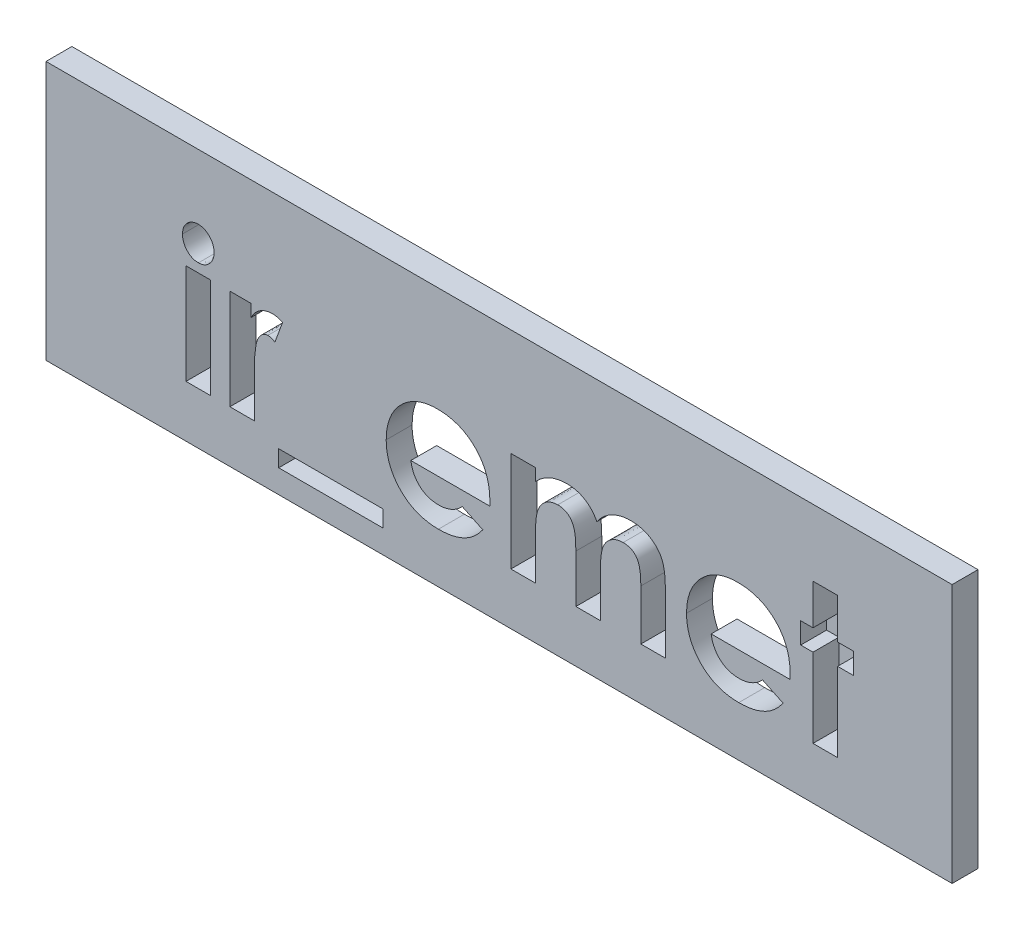
from build123d import *

# Parameters (mm, degrees)
ESQUISSE1_W             = 35
ESQUISSE1_H             = 10
BOSS_EXTRU_1_DEPTH      = 1
ESQUISSE2_R             = 1
BOSS_EXTRU_2_DEPTH      = 3
CHANFREIN1_SIZE         = 0.5
ESQUISSE3_W             = 0.949786325
ESQUISSE3_H             = 3.866987179
ESQUISSE3_W_2           = 3.731303419
ESQUISSE3_H_2           = 0.339209402
ENL_V_MAT_EXTRU_2_DEPTH = 1
ESQUISSE4_W             = 4.031303419
ESQUISSE4_H             = 0.639209402
ENL_V_MAT_EXTRU_3_DEPTH = 5


with BuildPart() as part:
    # Esquisse1 → Boss.-Extru.1 (new body)
    with BuildSketch(Plane.XY):
        with Locations((17.5, -5)):
            Rectangle(ESQUISSE1_W, ESQUISSE1_H)
    extrude(amount=BOSS_EXTRU_1_DEPTH)

    # Esquisse2 → Boss.-Extru.2 (add)
    with BuildSketch(Plane(origin=(0, 0, 0), x_dir=(-1, 0, 0), z_dir=(0, 0, -1))):
        with Locations(Location((-30, -5, 0), (0, 0, 180))):  # turned: the seam where the file's is
            Circle(ESQUISSE2_R)
        with Locations(Location((-5, -5, 0), (0, 0, 180))):  # turned: the seam where the file's is
            Circle(ESQUISSE2_R)
    extrude(amount=BOSS_EXTRU_2_DEPTH)

    # Chanfrein1
    chanfrein1_edges = [part.edges().sort_by_distance(p)[0] for p in [
        (29, -5, -3),
        (4, -5, -3),
    ]]
    chamfer(chanfrein1_edges, length=CHANFREIN1_SIZE)

    # Esquisse3 → Enlèv. mat.-Extru.2 (cut)
    with BuildSketch(Plane.XY.offset(1)):
        with BuildLine():
            add(Edge.make_bspline(
                [(5.879824386, -2.504807692), (5.92076017, -2.506816157), (6.001141525, -2.51075997), (6.116298756, -2.549203379), (6.221989755, -2.609539161), (6.315423529, -2.692321292), (6.393133006, -2.791178297), (6.452505932, -2.901855287), (6.485580115, -3.024481827), (6.49017363, -3.109190958), (6.492521368, -3.152485644)],
                knots=[0, 0, 0, 0, 0.989868614, 1.943702388, 2.910836514, 3.924849579, 4.949916355, 5.946401046, 6.950409252, 8, 8, 8, 8], degree=3))
            add(Edge.make_bspline(
                [(6.492521368, -3.152485644), (6.490257628, -3.195461271), (6.485846625, -3.279201328), (6.451744709, -3.400163155), (6.394754806, -3.510786389), (6.316415931, -3.608175184), (6.223995101, -3.68962406), (6.120613531, -3.751055201), (6.006559841, -3.787360012), (5.927425761, -3.791633507), (5.887244591, -3.793803419)],
                knots=[0, 0, 0, 0, 1.05296456, 2.051751585, 3.055639087, 4.085634717, 5.099016424, 6.062201612, 7.016062274, 8, 8, 8, 8], degree=3))
            add(Edge.make_bspline(
                [(5.887244591, -3.793803419), (5.845951472, -3.791802134), (5.764870802, -3.787872533), (5.648769045, -3.749339175), (5.541668398, -3.689478577), (5.448639939, -3.605005079), (5.370040515, -3.50544562), (5.313261022, -3.392191974), (5.277744044, -3.268726916), (5.27352821, -3.182763185), (5.271367521, -3.138705262)],
                knots=[0, 0, 0, 0, 0.989065327, 1.942068821, 2.907541208, 3.917690034, 4.939857478, 5.938239964, 6.943311734, 8, 8, 8, 8], degree=3))
            add(Edge.make_bspline(
                [(5.271367521, -3.138705262), (5.273718942, -3.096459386), (5.278337968, -3.013473462), (5.31161027, -2.893573269), (5.369621776, -2.784756933), (5.446771504, -2.687709598), (5.539384615, -2.606471665), (5.645012166, -2.547968321), (5.759394385, -2.511112734), (5.839266553, -2.506931074), (5.879824386, -2.504807692)],
                knots=[0, 0, 0, 0, 1.038616768, 2.040212704, 3.031499824, 4.052181184, 5.074969369, 6.039807101, 7.004644834, 8, 8, 8, 8], degree=3))
        make_face()
        with Locations((5.881944445, -6.066506411)):
            Rectangle(ESQUISSE3_W, ESQUISSE3_H)
        with BuildLine():
            Line((7.103098291, -4.133012821), (7.917200855, -4.133012821))
            Line((7.917200855, -4.133012821), (7.917200855, -4.608966012))
            add(Edge.make_bspline(
                [(7.917200855, -4.608966012), (7.940230253, -4.566667921), (7.985242169, -4.483994547), (8.067932832, -4.373021915), (8.162931215, -4.27956386), (8.266823732, -4.201665623), (8.379925261, -4.140951595), (8.499207145, -4.097685197), (8.623648929, -4.069568033), (8.708538895, -4.066647192), (8.751443977, -4.06517094)],
                knots=[0, 0, 0, 0, 1.09866127, 2.147379032, 3.14564304, 4.131443017, 5.102343063, 6.064490016, 7.021754664, 8, 8, 8, 8], degree=3))
            add(Edge.make_bspline(
                [(8.751443977, -4.06517094), (8.78259842, -4.066629785), (8.84603999, -4.069600514), (8.942733871, -4.086869409), (9.040822874, -4.118094854), (9.105373891, -4.146209218), (9.138354701, -4.160573584)],
                knots=[0, 0, 0, 0, 0.931404136, 1.896671404, 2.925354185, 4, 4, 4, 4], degree=3))
            Line((9.138354701, -4.160573584), (8.843666533, -4.965135884))
            add(Edge.make_bspline(
                [(8.843666533, -4.965135884), (8.817325619, -4.952409228), (8.767814841, -4.928488014), (8.695933787, -4.900258516), (8.630698751, -4.883034257), (8.589340935, -4.880464246), (8.570178953, -4.879273504)],
                knots=[0, 0, 0, 0, 1.214386998, 2.282580073, 3.20428172, 4, 4, 4, 4], degree=3))
            add(Edge.make_bspline(
                [(8.570178953, -4.879273504), (8.552086315, -4.880062553), (8.51649498, -4.881614748), (8.463963165, -4.894916529), (8.414489134, -4.917855038), (8.365688737, -4.947241545), (8.321411784, -4.988090988), (8.277162179, -5.03538147), (8.238167059, -5.093767862), (8.197015897, -5.15875488), (8.161977155, -5.238298932), (8.131932512, -5.333258138), (8.105162494, -5.444731242), (8.086741067, -5.57331011), (8.068936018, -5.717750521), (8.058338015, -5.879112649), (8.05043919, -6.056886251), (8.04995623, -6.180978642), (8.049704527, -6.245651376)],
                knots=[0, 0, 0, 0, 0.544232178, 1.070598461, 1.618251235, 2.182094276, 2.777567932, 3.425210017, 4.127676488, 4.886675562, 5.738955394, 6.734782583, 7.883056018, 9.186093582, 10.642914445, 12.264202625, 14.053029461, 16, 16, 16, 16], degree=3))
            Line((8.049704527, -6.245651376), (8.052884615, -6.434336605))
            Line((8.052884615, -6.434336605), (8.052884615, -8))
            Line((8.052884615, -8), (7.103098291, -8))
            Line((7.103098291, -8), (7.103098291, -4.133012821))
        make_face()
        with Locations((11.004006411, -8.780181624)):
            Rectangle(ESQUISSE3_W_2, ESQUISSE3_H_2)
        with BuildLine():
            Line((17.140516493, -6.303952991), (14.090811966, -6.303952991))
            add(Edge.make_bspline(
                [(14.090811966, -6.303952991), (14.097030067, -6.339388828), (14.109249127, -6.409023042), (14.135783249, -6.510172781), (14.169644768, -6.605494587), (14.210225667, -6.695115884), (14.256841751, -6.779510462), (14.311215552, -6.858282479), (14.372657386, -6.931362358), (14.440812014, -6.998432487), (14.514543421, -7.058528775), (14.593494038, -7.111176923), (14.677745337, -7.154345184), (14.766331408, -7.190731548), (14.859914193, -7.219553234), (14.958631422, -7.239431004), (15.062221412, -7.251172875), (15.132790077, -7.252871202), (15.168861846, -7.253739316)],
                knots=[0, 0, 0, 0, 1.091296461, 2.144483647, 3.168565212, 4.157007626, 5.126487748, 6.090021542, 7.05641414, 8.019231907, 8.98705074, 9.938580405, 10.892824166, 11.854447369, 12.841318655, 13.858982407, 14.905600794, 16, 16, 16, 16], degree=3))
            add(Edge.make_bspline(
                [(15.168861846, -7.253739316), (15.212402919, -7.25258979), (15.298148115, -7.250326034), (15.423765466, -7.23024988), (15.545255743, -7.199925733), (15.66146922, -7.15483118), (15.773752046, -7.098696389), (15.880255704, -7.028759346), (15.982823686, -6.947063841), (16.045402242, -6.884092976), (16.077307025, -6.851988181)],
                knots=[0, 0, 0, 0, 1.021034703, 2.010718019, 2.977989445, 3.954245119, 4.929443971, 5.918328161, 6.938689359, 8, 8, 8, 8], degree=3))
            Line((16.077307025, -6.851988181), (16.87232906, -7.23041867))
            add(Edge.make_bspline(
                [(16.87232906, -7.23041867), (16.847298255, -7.2650074), (16.797700636, -7.333543698), (16.716734187, -7.42999197), (16.632240542, -7.51998212), (16.544156686, -7.602922269), (16.452370906, -7.678576072), (16.357138528, -7.747865128), (16.257067769, -7.808929053), (16.154159528, -7.864722083), (16.046286499, -7.91255319), (15.933747216, -7.953341869), (15.817018344, -7.990214488), (15.694625851, -8.018309404), (15.567588898, -8.04054911), (15.435603588, -8.056342248), (15.298687315, -8.066096912), (15.205626122, -8.067253315), (15.158261552, -8.06784188)],
                knots=[0, 0, 0, 0, 1.028154879, 2.037251081, 3.030720504, 4.000128189, 4.949298328, 5.894184978, 6.834267904, 7.770992897, 8.712077017, 9.673380525, 10.653304757, 11.658697181, 12.695551717, 13.758623199, 14.859225354, 16, 16, 16, 16], degree=3))
            add(Edge.make_bspline(
                [(15.158261552, -8.06784188), (15.085391938, -8.066356288), (14.942680999, -8.063446841), (14.733940453, -8.036443012), (14.53569483, -7.991667753), (14.347384355, -7.930802664), (14.16982303, -7.85044168), (14.00292298, -7.752153529), (13.845016634, -7.637822594), (13.700928914, -7.505049371), (13.56966075, -7.360533612), (13.454362956, -7.205333555), (13.357883404, -7.040533524), (13.278652456, -6.867224201), (13.217071411, -6.684961981), (13.172675049, -6.49366733), (13.145459547, -6.293431612), (13.142520138, -6.157048736), (13.141025641, -6.087706998)],
                knots=[0, 0, 0, 0, 1.103565453, 2.161269334, 3.182010356, 4.179077853, 5.15417608, 6.128274628, 7.109042802, 8.101804412, 9.090965879, 10.063106201, 11.02526161, 11.978650795, 12.945248442, 13.93468508, 14.949922959, 16, 16, 16, 16], degree=3))
            add(Edge.make_bspline(
                [(13.141025641, -6.087706998), (13.142534847, -6.016603197), (13.145504141, -5.876709662), (13.172440723, -5.67185041), (13.217194151, -5.476386975), (13.278955335, -5.290050184), (13.35698434, -5.112257255), (13.454691429, -4.944563662), (13.569603534, -4.786385588), (13.700398807, -4.638463007), (13.845096927, -4.504946716), (13.998852351, -4.385957019), (14.163392677, -4.286806905), (14.336856814, -4.206693674), (14.518135222, -4.141603697), (14.709323225, -4.098291753), (14.908966176, -4.069210375), (15.045437701, -4.066532162), (15.114800347, -4.06517094)],
                knots=[0, 0, 0, 0, 1.079208495, 2.12329425, 3.130605359, 4.119693003, 5.099659317, 6.073216462, 7.060498243, 8.06384408, 9.066070512, 10.045757761, 11.010926815, 11.975797609, 12.942977511, 13.929384301, 14.947594487, 16, 16, 16, 16], degree=3))
            add(Edge.make_bspline(
                [(15.114800347, -4.06517094), (15.188019056, -4.06667958), (15.331776445, -4.06964164), (15.541970805, -4.096426204), (15.741532754, -4.141474498), (15.93131254, -4.201813297), (16.108886594, -4.284204284), (16.27815676, -4.380073719), (16.435062976, -4.496876004), (16.581277698, -4.628999478), (16.713266367, -4.775585892), (16.828639088, -4.934823635), (16.926807074, -5.105158639), (17.0063732, -5.287281648), (17.067891013, -5.480645912), (17.112328472, -5.68500031), (17.139336384, -5.901122106), (17.142221098, -6.049113087), (17.143696581, -6.124808026)],
                knots=[0, 0, 0, 0, 1.080001299, 2.120471247, 3.119684163, 4.095710327, 5.052285597, 6.002875087, 6.961153713, 7.931888285, 8.906493152, 9.865905668, 10.82813294, 11.801621613, 12.7925306, 13.817193356, 14.883530496, 16, 16, 16, 16], degree=3))
            Line((17.143696581, -6.124808026), (17.140516493, -6.303952991))
        make_face()
        with BuildLine():
            Line((17.957799145, -4.133012821), (18.90758547, -4.133012821))
            Line((18.90758547, -4.133012821), (18.90758547, -4.59518563))
            add(Edge.make_bspline(
                [(18.90758547, -4.59518563), (18.949831483, -4.552547263), (19.033010411, -4.468595821), (19.170854165, -4.360668696), (19.314639159, -4.268377671), (19.466107838, -4.193662277), (19.624889717, -4.136611678), (19.790232251, -4.09480584), (19.962984709, -4.070141705), (20.080605785, -4.066846229), (20.140399639, -4.06517094)],
                knots=[0, 0, 0, 0, 1.041528618, 2.050684245, 3.032913108, 4.004406485, 4.976926473, 5.95771665, 6.961784757, 8, 8, 8, 8], degree=3))
            add(Edge.make_bspline(
                [(20.140399639, -4.06517094), (20.200272443, -4.067054206), (20.31813012, -4.070761355), (20.49008365, -4.104685241), (20.652982147, -4.159800091), (20.805033343, -4.238359539), (20.947336177, -4.335376374), (21.073586538, -4.45586279), (21.187227035, -4.595022486), (21.247801795, -4.700228713), (21.278871194, -4.754190037)],
                knots=[0, 0, 0, 0, 1.023965777, 2.015643508, 2.987309376, 3.958410333, 4.93654923, 5.924956801, 6.93568961, 8, 8, 8, 8], degree=3))
            add(Edge.make_bspline(
                [(21.278871194, -4.754190037), (21.318892595, -4.700081917), (21.397443375, -4.593882862), (21.536681787, -4.455227954), (21.687240052, -4.33536381), (21.852031126, -4.237643293), (22.02667873, -4.160068241), (22.210418627, -4.104890023), (22.40158497, -4.070818051), (22.531684157, -4.067068949), (22.597547743, -4.06517094)],
                knots=[0, 0, 0, 0, 1.041189987, 2.043563759, 3.033412161, 4.015238574, 5.00275396, 5.986226558, 6.980513695, 8, 8, 8, 8], degree=3))
            add(Edge.make_bspline(
                [(22.597547743, -4.06517094), (22.665577006, -4.067141729), (22.798057671, -4.070979658), (22.990041178, -4.108738156), (23.169856965, -4.167080701), (23.333531152, -4.251983383), (23.481530555, -4.352553973), (23.607643899, -4.471382321), (23.712306452, -4.604321999), (23.780455196, -4.728455222), (23.824511527, -4.838203205), (23.851113132, -4.933704514), (23.875993863, -5.040343805), (23.893868178, -5.159554459), (23.910553062, -5.290215988), (23.920239294, -5.433197075), (23.926823126, -5.588016049), (23.927522412, -5.695134454), (23.927884615, -5.750617655)],
                knots=[0, 0, 0, 0, 1.321991808, 2.574456155, 3.791773975, 4.987670122, 6.148905103, 7.262530793, 8.344737981, 9.427709016, 10.004683293, 10.642050061, 11.354108788, 12.133887687, 12.985666279, 13.916212488, 14.92067847, 16, 16, 16, 16], degree=3))
            Line((23.927884615, -5.750617655), (23.927884615, -8))
            Line((23.927884615, -8), (22.978098291, -8))
            Line((22.978098291, -8), (22.978098291, -6.058026175))
            add(Edge.make_bspline(
                [(22.978098291, -6.058026175), (22.977307773, -6.006081985), (22.975790447, -5.906379806), (22.969339708, -5.763376066), (22.954900195, -5.633684014), (22.937975235, -5.516585277), (22.913755291, -5.412700728), (22.884223467, -5.321779938), (22.849966731, -5.243692031), (22.808602754, -5.178445146), (22.762275052, -5.123496962), (22.710742167, -5.076395486), (22.654541407, -5.036208607), (22.59316323, -5.001955004), (22.524999686, -4.978788614), (22.452351868, -4.960611438), (22.374651285, -4.948232651), (22.32092912, -4.947494664), (22.293319311, -4.947115385)],
                knots=[0, 0, 0, 0, 1.669139205, 3.203761885, 4.596586177, 5.860166715, 7.002923539, 8.018877315, 8.928339525, 9.734594377, 10.491888885, 11.231098709, 11.971440889, 12.708030942, 13.480072485, 14.275788656, 15.113863979, 16, 16, 16, 16], degree=3))
            add(Edge.make_bspline(
                [(22.293319311, -4.947115385), (22.250772986, -4.948586321), (22.16728429, -4.951472742), (22.045624244, -4.979055723), (21.931141244, -5.024150945), (21.824264191, -5.085499), (21.727292842, -5.162121562), (21.642467458, -5.253003227), (21.572413521, -5.358667753), (21.523920478, -5.456703237), (21.493618418, -5.545347015), (21.472243068, -5.621263291), (21.455581833, -5.707113371), (21.442540964, -5.802027791), (21.430029772, -5.906543112), (21.423891852, -6.02052717), (21.417610887, -6.143821616), (21.417692652, -6.229033939), (21.417735043, -6.273212139)],
                knots=[0, 0, 0, 0, 1.129913425, 2.217230253, 3.297175357, 4.391411011, 5.481605898, 6.571841268, 7.681894157, 8.841607612, 9.468549532, 10.170608623, 10.93710061, 11.791434153, 12.717934886, 13.734733707, 14.825576123, 16, 16, 16, 16], degree=3))
            Line((21.417735043, -6.273212139), (21.417735043, -8))
            Line((21.417735043, -8), (20.467948718, -8))
            Line((20.467948718, -8), (20.467948718, -6.146008614))
            add(Edge.make_bspline(
                [(20.467948718, -6.146008614), (20.467868974, -6.104662165), (20.467715571, -6.02512499), (20.463104606, -5.910271787), (20.456998786, -5.804220605), (20.448439138, -5.706675648), (20.438567269, -5.617758237), (20.424319888, -5.537954814), (20.4093517, -5.466825637), (20.383688538, -5.386025014), (20.347525843, -5.296484401), (20.293498249, -5.201531568), (20.228171508, -5.122030947), (20.15319675, -5.057363855), (20.068472057, -5.00809272), (19.976143769, -4.971441119), (19.874448934, -4.95165771), (19.804449008, -4.948661445), (19.768329327, -4.947115385)],
                knots=[0, 0, 0, 0, 1.256487322, 2.417074606, 3.49288742, 4.484586665, 5.393016842, 6.210437544, 6.947749329, 7.599905853, 8.784490193, 9.876739139, 10.906602197, 11.896672079, 12.869113195, 13.872201355, 14.902064413, 16, 16, 16, 16], degree=3))
            add(Edge.make_bspline(
                [(19.768329327, -4.947115385), (19.727517195, -4.948500619), (19.646688426, -4.951244088), (19.528948977, -4.980711182), (19.416379144, -5.024978991), (19.31145535, -5.088038137), (19.215944879, -5.166463861), (19.131968779, -5.259930578), (19.062283002, -5.36832742), (19.013574707, -5.469067075), (18.983714487, -5.559922392), (18.961764385, -5.637809906), (18.945723053, -5.725550598), (18.93233904, -5.822159294), (18.91990192, -5.927750032), (18.913738603, -6.042787158), (18.907463844, -6.167143162), (18.907543951, -6.253061473), (18.90758547, -6.297592815)],
                knots=[0, 0, 0, 0, 1.07893236, 2.136834559, 3.195274846, 4.273923004, 5.364443877, 6.458052972, 7.587287137, 8.767908, 9.410170275, 10.118584836, 10.909717261, 11.770069756, 12.702352573, 13.724628867, 14.820678298, 16, 16, 16, 16], degree=3))
            Line((18.90758547, -6.297592815), (18.90758547, -8))
            Line((18.90758547, -8), (17.957799145, -8))
            Line((17.957799145, -8), (17.957799145, -4.133012821))
        make_face()
        with BuildLine():
            Line((28.741478032, -6.303952991), (25.691773504, -6.303952991))
            add(Edge.make_bspline(
                [(25.691773504, -6.303952991), (25.697991606, -6.339388828), (25.710210665, -6.409023042), (25.736744787, -6.510172781), (25.770606307, -6.605494587), (25.811187206, -6.695115884), (25.85780329, -6.779510462), (25.91217709, -6.858282479), (25.973618925, -6.931362358), (26.041773552, -6.998432487), (26.11550496, -7.058528775), (26.194455577, -7.111176923), (26.278706875, -7.154345184), (26.367292946, -7.190731548), (26.460875731, -7.219553234), (26.559592961, -7.239431004), (26.66318295, -7.251172875), (26.733751615, -7.252871202), (26.769823384, -7.253739316)],
                knots=[0, 0, 0, 0, 1.091296461, 2.144483647, 3.168565212, 4.157007626, 5.126487748, 6.090021542, 7.05641414, 8.019231907, 8.98705074, 9.938580405, 10.892824166, 11.854447369, 12.841318655, 13.858982407, 14.905600794, 16, 16, 16, 16], degree=3))
            add(Edge.make_bspline(
                [(26.769823384, -7.253739316), (26.813364458, -7.25258979), (26.899109654, -7.250326034), (27.024727005, -7.23024988), (27.146217282, -7.199925733), (27.262430758, -7.15483118), (27.374713585, -7.098696389), (27.481217242, -7.028759346), (27.583785224, -6.947063841), (27.64636378, -6.884092976), (27.678268563, -6.851988181)],
                knots=[0, 0, 0, 0, 1.021034703, 2.010718019, 2.977989445, 3.954245119, 4.929443971, 5.918328161, 6.938689359, 8, 8, 8, 8], degree=3))
            Line((27.678268563, -6.851988181), (28.473290598, -7.23041867))
            add(Edge.make_bspline(
                [(28.473290598, -7.23041867), (28.448259794, -7.2650074), (28.398662174, -7.333543698), (28.317695726, -7.42999197), (28.23320208, -7.51998212), (28.145118224, -7.602922269), (28.053332444, -7.678576072), (27.958100066, -7.747865128), (27.858029308, -7.808929053), (27.755121066, -7.864722083), (27.647248038, -7.91255319), (27.534708754, -7.953341869), (27.417979882, -7.990214488), (27.29558739, -8.018309404), (27.168550437, -8.04054911), (27.036565126, -8.056342248), (26.899648854, -8.066096912), (26.806587661, -8.067253315), (26.75922309, -8.06784188)],
                knots=[0, 0, 0, 0, 1.028154879, 2.037251081, 3.030720504, 4.000128189, 4.949298328, 5.894184978, 6.834267904, 7.770992897, 8.712077017, 9.673380525, 10.653304757, 11.658697181, 12.695551717, 13.758623199, 14.859225354, 16, 16, 16, 16], degree=3))
            add(Edge.make_bspline(
                [(26.75922309, -8.06784188), (26.686353476, -8.066356288), (26.543642538, -8.063446841), (26.334901991, -8.036443012), (26.136656369, -7.991667753), (25.948345893, -7.930802664), (25.770784568, -7.85044168), (25.603884518, -7.752153529), (25.445978173, -7.637822594), (25.301890452, -7.505049371), (25.170622288, -7.360533612), (25.055324495, -7.205333555), (24.958844943, -7.040533524), (24.879613995, -6.867224201), (24.818032949, -6.684961981), (24.773636587, -6.49366733), (24.746421085, -6.293431612), (24.743481676, -6.157048736), (24.741987179, -6.087706998)],
                knots=[0, 0, 0, 0, 1.103565453, 2.161269334, 3.182010356, 4.179077853, 5.15417608, 6.128274628, 7.109042802, 8.101804412, 9.090965879, 10.063106201, 11.02526161, 11.978650795, 12.945248442, 13.93468508, 14.949922959, 16, 16, 16, 16], degree=3))
            add(Edge.make_bspline(
                [(24.741987179, -6.087706998), (24.743496385, -6.016603197), (24.746465679, -5.876709662), (24.773402262, -5.67185041), (24.81815569, -5.476386975), (24.879916873, -5.290050184), (24.957945878, -5.112257255), (25.055652967, -4.944563662), (25.170565072, -4.786385588), (25.301360346, -4.638463007), (25.446058466, -4.504946716), (25.599813889, -4.385957019), (25.764354216, -4.286806905), (25.937818352, -4.206693674), (26.11909676, -4.141603697), (26.310284764, -4.098291753), (26.509927714, -4.069210375), (26.646399239, -4.066532162), (26.715761886, -4.06517094)],
                knots=[0, 0, 0, 0, 1.079208495, 2.12329425, 3.130605359, 4.119693003, 5.099659317, 6.073216462, 7.060498243, 8.06384408, 9.066070512, 10.045757761, 11.010926815, 11.975797609, 12.942977511, 13.929384301, 14.947594487, 16, 16, 16, 16], degree=3))
            add(Edge.make_bspline(
                [(26.715761886, -4.06517094), (26.788980594, -4.06667958), (26.932737983, -4.06964164), (27.142932343, -4.096426204), (27.342494293, -4.141474498), (27.532274078, -4.201813297), (27.709848133, -4.284204284), (27.879118298, -4.380073719), (28.036024515, -4.496876004), (28.182239237, -4.628999478), (28.314227905, -4.775585892), (28.429600626, -4.934823635), (28.527768612, -5.105158639), (28.607334739, -5.287281648), (28.668852552, -5.480645912), (28.713290011, -5.68500031), (28.740297923, -5.901122106), (28.743182636, -6.049113087), (28.74465812, -6.124808026)],
                knots=[0, 0, 0, 0, 1.080001299, 2.120471247, 3.119684163, 4.095710327, 5.052285597, 6.002875087, 6.961153713, 7.931888285, 8.906493152, 9.865905668, 10.82813294, 11.801621613, 12.7925306, 13.817193356, 14.883530496, 16, 16, 16, 16], degree=3))
            Line((28.74465812, -6.124808026), (28.741478032, -6.303952991))
        make_face()
        Polygon((29.626602564, -2.572649573), (30.576388889, -2.572649573), (30.576388889, -4.133012821), (31.186965812, -4.133012821), (31.186965812, -4.947115385), (30.576388889, -4.947115385), (30.576388889, -8), (29.626602564, -8), (29.626602564, -4.947115385), (29.151709402, -4.947115385), (29.151709402, -4.133012821), (29.626602564, -4.133012821), align=None)
    extrude(amount=-ENL_V_MAT_EXTRU_2_DEPTH, mode=Mode.SUBTRACT)

    # Esquisse4 → Enlèv. mat.-Extru.3 (cut, through all)
    with BuildSketch(Plane.XY.offset(1)):
        with Locations((11.004006411, -8.780181624)):
            Rectangle(ESQUISSE4_W, ESQUISSE4_H)
    extrude(amount=-ENL_V_MAT_EXTRU_3_DEPTH, mode=Mode.SUBTRACT)


solid = part.part
